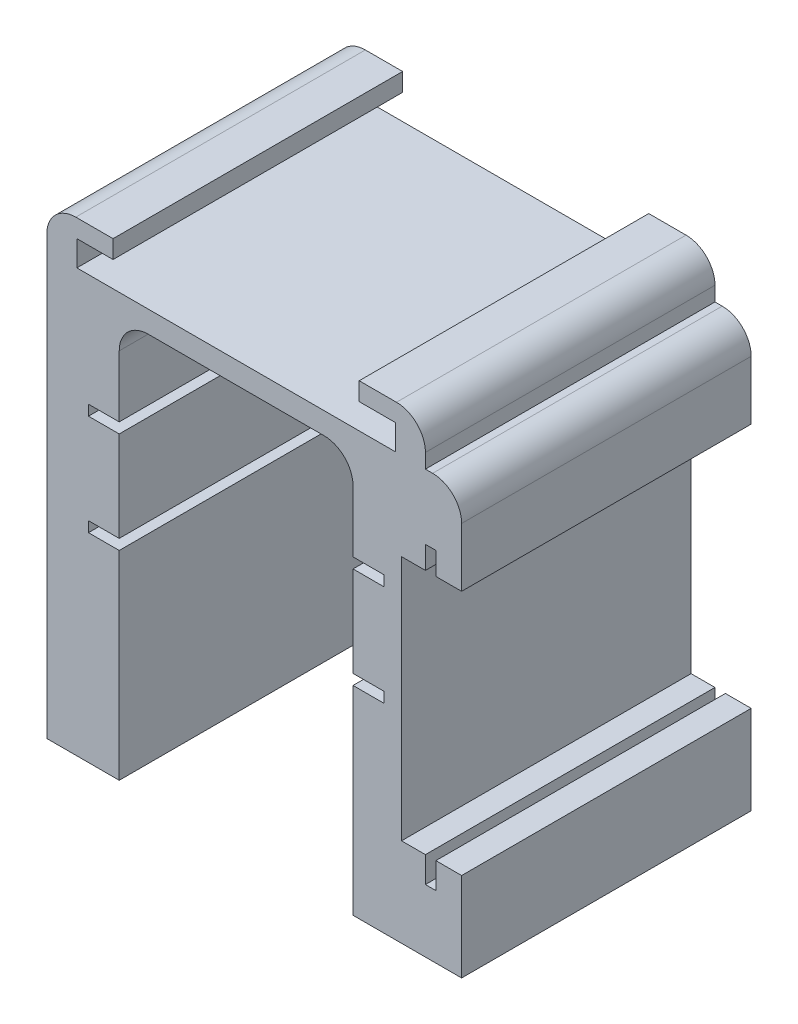
from build123d import *

# Parameters (mm, degrees)
BOSS_EXTRUDE1_DEPTH = 50.8
SKETCH2_R           = 2.6035
CUT_EXTRUDE1_DEPTH  = 5.08
FILLET1_R           = 5.08


with BuildPart() as part:
    # Sketch1 → Boss-Extrude1 (new body)
    with BuildSketch(Plane.XY):
        Polygon((12.7, 54.4576), (12.7, 70.3326), (53.721, 70.3326), (53.721, 54.4576), (59.1185, 54.4576), (59.1185, 52.6288), (53.721, 52.6288), (53.721, 36.7538), (59.1185, 36.7538), (59.1185, 34.925), (53.721, 34.925), (53.721, 0), (72.771, 0), (72.771, 15.572598677), (68.2498, 15.572598677), (68.2498, 11.0236), (66.421, 11.0236), (66.421, 15.572598677), (62.23, 15.572598677), (62.23, 58.752598677), (66.421, 58.752598677), (66.421, 62.7126), (68.2498, 62.7126), (68.2498, 58.752598677), (72.771, 58.752598677), (72.771, 74.1426), (66.421, 74.1426), (66.421, 81.7626), (54.8005, 81.7626), (54.8005, 78.5876), (61.1505, 78.5876), (61.1505, 74.1426), (5.2705, 74.1426), (5.2705, 78.5876), (11.6205, 78.5876), (11.6205, 81.7626), (0, 81.7626), (0, 0), (12.7, 0), (12.7, 34.925), (7.3025, 34.925), (7.3025, 36.7538), (12.7, 36.7538), (12.7, 52.6288), (7.3025, 52.6288), (7.3025, 54.4576), align=None)
    extrude(amount=BOSS_EXTRUDE1_DEPTH)

    # Sketch2 → Cut-Extrude1 (cut)
    with BuildSketch(Plane.XZ):
        with Locations((6.35, 44.45)):
            Circle(SKETCH2_R)
        with Locations((66.421, 6.35)):
            Circle(SKETCH2_R)
    extrude(amount=-CUT_EXTRUDE1_DEPTH, mode=Mode.SUBTRACT)

    # Fillet1
    fillet1_edges = [part.edges().sort_by_distance(p)[0] for p in [
        (53.721, 70.3326, 25.4),
        (12.7, 70.3326, 25.4),
        (0, 81.7626, 25.4),
        (66.421, 81.7626, 25.4),
        (72.771, 74.1426, 25.4),
    ]]
    fillet(fillet1_edges, radius=FILLET1_R)


solid = part.part
